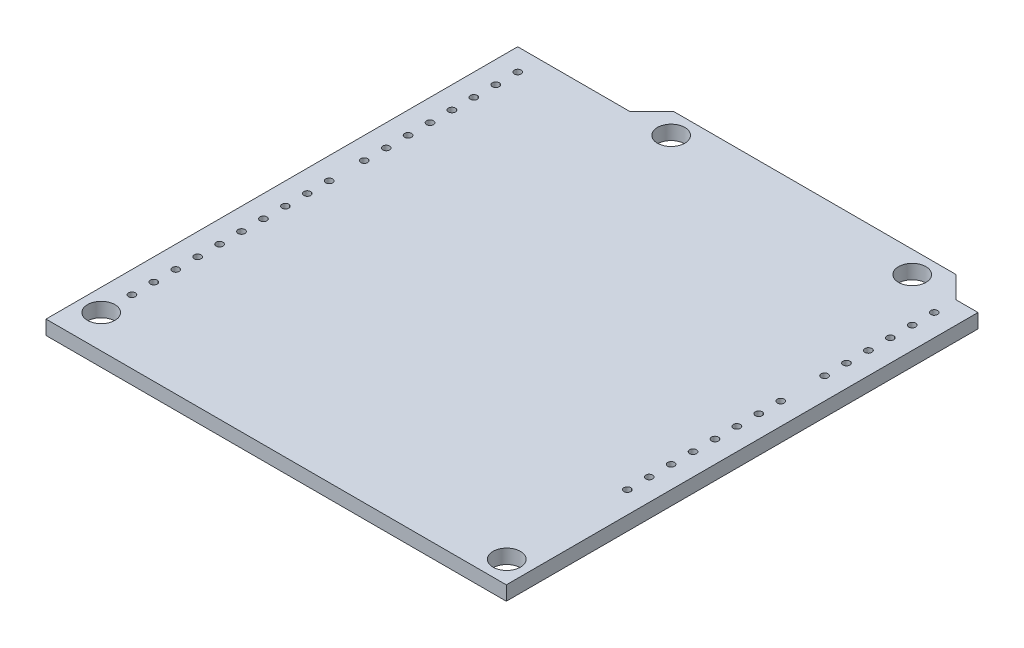
from build123d import *

# Parameters (mm, degrees)
SKETCH1_R             = 1.5875
BOSS_EXTRUDE1_DEPTH   = 1.65
SKETCH2_R             = 0.4
CUT_EXTRUDE1_DEPTH    = 1.65
SKETCH3_R             = 0.4
CUT_EXTRUDE2_DEPTH    = 1.65
LPATTERN1_COUNT       = 15
LPATTERN1_PITCH       = 2.54
SKETCH4_R             = 0.4
CUT_EXTRUDE3_DEPTH    = 1.65
LPATTERN2_COUNT       = 10
LPATTERN2_PITCH       = 2.54
LPATTERN3_COUNT       = 8
LPATTERN3_PITCH       = 2.54
CROQUIS1_W            = 53.34
CROQUIS1_H            = 11.38
CORTAR_EXTRUIR1_DEPTH = 1.65


with BuildPart() as part:
    # Sketch1 → Boss-Extrude1 (new body)
    with BuildSketch(Plane(origin=(0, 0, 0), x_dir=(1, 0, 0), z_dir=(0, 1, 0))):
        Polygon((0, 0), (-53.34, 0), (-53.34, 66.04), (-40.386, 66.04), (-37.846, 68.58), (-5.08, 68.58), (-2.54, 66.04), (0, 66.04), align=None)
        with Locations((-7.62, 66.04)):
            Circle(SKETCH1_R, mode=Mode.SUBTRACT)
        with Locations((-35.56, 66.04)):
            Circle(SKETCH1_R, mode=Mode.SUBTRACT)
        with Locations((-2.54, 13.97)):
            Circle(SKETCH1_R, mode=Mode.SUBTRACT)
        with Locations((-50.8, 15.24)):
            Circle(SKETCH1_R, mode=Mode.SUBTRACT)
    extrude(amount=-BOSS_EXTRUDE1_DEPTH)

    # Sketch2 → Cut-Extrude1 (cut)
    with BuildSketch(Plane(origin=(0, 0, 0), x_dir=(1, 0, 0), z_dir=(0, 1, 0))):
        with Locations((-2.54, 27.94)):
            Circle(SKETCH2_R)
    cut_extrude1 = extrude(amount=-CUT_EXTRUDE1_DEPTH, mode=Mode.SUBTRACT)

    # Sketch3 → Cut-Extrude2 (cut)
    with BuildSketch(Plane(origin=(0, 0, 0), x_dir=(1, 0, 0), z_dir=(0, 1, 0))):
        with Locations((-50.8, 18.796)):
            Circle(SKETCH3_R)
    cut_extrude2 = extrude(amount=-CUT_EXTRUDE2_DEPTH, mode=Mode.SUBTRACT)

    # LPattern1: Cut-Extrude1 ×15, 1 skipped
    with Locations(*[(0, 0, -i * LPATTERN1_PITCH) for i in range(1, LPATTERN1_COUNT) if i not in (8,)]):
        add(cut_extrude1, mode=Mode.SUBTRACT)

    # Sketch4 → Cut-Extrude3 (cut)
    with BuildSketch(Plane(origin=(0, 0, 0), x_dir=(1, 0, 0), z_dir=(0, 1, 0))):
        with Locations((-50.8, 45.72)):
            Circle(SKETCH4_R)
    cut_extrude3 = extrude(amount=-CUT_EXTRUDE3_DEPTH, mode=Mode.SUBTRACT)

    # LPattern2: Cut-Extrude2 ×10
    with Locations(*[(0, 0, -i * LPATTERN2_PITCH) for i in range(1, LPATTERN2_COUNT)]):
        add(cut_extrude2, mode=Mode.SUBTRACT)

    # LPattern3: Cut-Extrude3 ×8
    with Locations(*[(0, 0, -i * LPATTERN3_PITCH) for i in range(1, LPATTERN3_COUNT)]):
        add(cut_extrude3, mode=Mode.SUBTRACT)

    # Croquis1 → Cortar-Extruir1 (cut)
    with BuildSketch(Plane(origin=(0, 0, 0), x_dir=(1, 0, 0), z_dir=(0, 1, 0))):
        with Locations((-26.67, 5.69)):
            Rectangle(CROQUIS1_W, CROQUIS1_H)
    extrude(amount=-CORTAR_EXTRUIR1_DEPTH, mode=Mode.SUBTRACT)


solid = part.part
